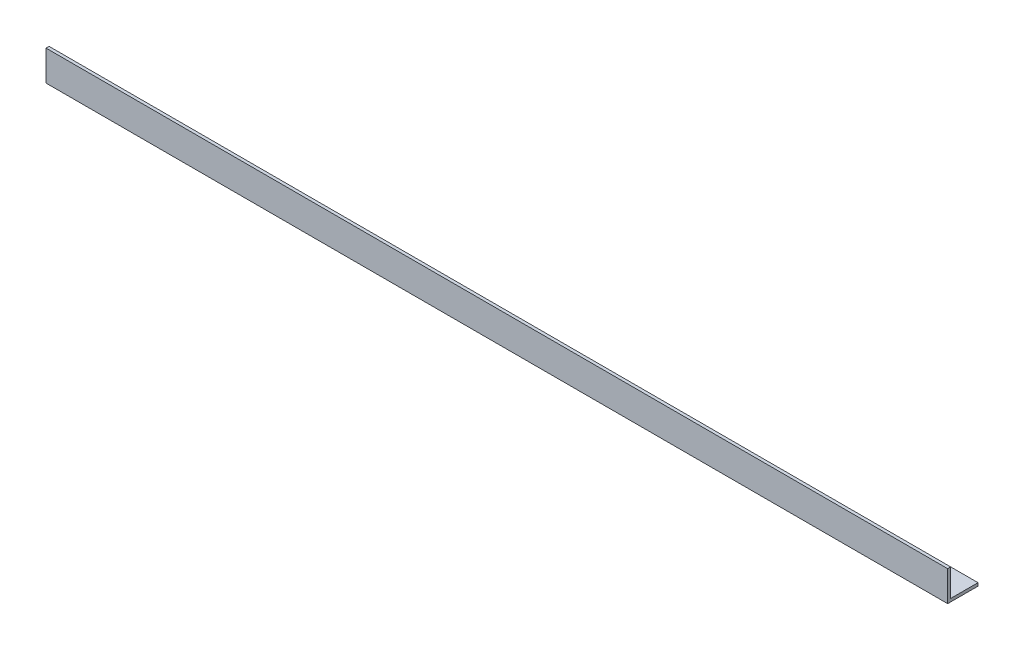
from build123d import *

# Parameters (mm, degrees)
EXTRUDE_1_DEPTH = 446


with BuildPart() as part:
    # Эскиз1 → Бобышка-Вытянуть1 (new body)
    with BuildSketch(Plane(origin=(0, 0, 0), x_dir=(0, 0, -1), z_dir=(1, 0, 0))):
        Polygon((0, 0), (0, 15), (1.5, 15), (1.5, 1.5), (15, 1.5), (15, 0), align=None)
    extrude(amount=EXTRUDE_1_DEPTH)


solid = part.part
